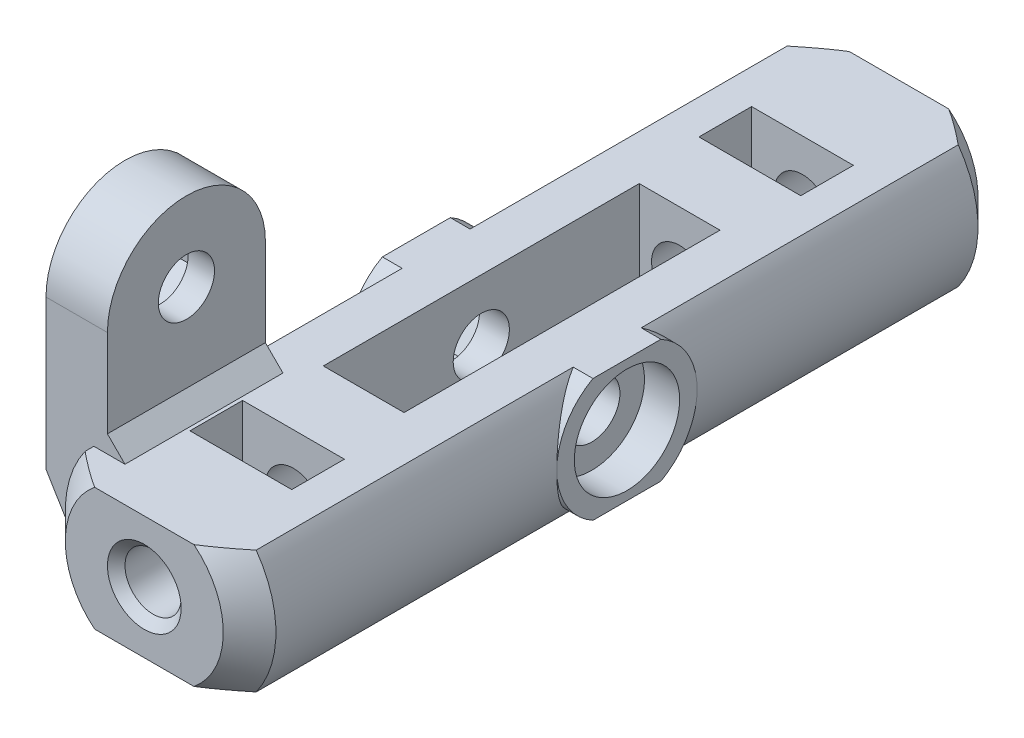
from build123d import *

# Parameters (mm, degrees)
BOSS_EXTRUDE1_DEPTH     = 21.5
BOSS_EXTRUDE2_DEPTH     = 6
CHAMFER1_SIZE           = 1.5
SKETCH2_W               = 4.6
SKETCH2_H               = 18
CUT_EXTRUDE1_DEPTH      = 4.5000001
CUT_EXTRUDE1_DEPTH_BACK = 4.5000001
SKETCH3_R               = 1.6
CUT_EXTRUDE2_DEPTH      = 16
CHAMFER2_SIZE           = 0.5
SKETCH4_R               = 1.6
CUT_EXTRUDE3_DEPTH      = 7.0000001
CUT_EXTRUDE3_DEPTH_BACK = 7.0000001
SKETCH6_R               = 3
CUT_EXTRUDE4_DEPTH      = 2
CUT_EXTRUDE5_DEPTH      = 2
BOSS_EXTRUDE3_START     = -4.1
SKETCH8_R               = 1.6
BOSS_EXTRUDE3_DEPTH     = 3.5
BOSS_EXTRUDE4_DEPTH     = 9
BOSS_EXTRUDE5_DEPTH     = 9
CUT_EXTRUDE6_DEPTH      = 2
SKETCH13_W              = 5.8
SKETCH13_H              = 3
CUT_EXTRUDE8_DEPTH      = 18.5


with BuildPart() as part:
    # Sketch1 → Boss-Extrude1 (new body, symmetric)
    with BuildSketch(Plane.XY):
        with BuildLine():
            Line((-4.873397172, 3.5), (4.873397172, 3.5))
            ThreePointArc((4.873397172, 3.5), (6, 0), (4.873397172, -3.5))
            Line((4.873397172, -3.5), (-4.873397172, -3.5))
            ThreePointArc((-4.873397172, -3.5), (-6, 0), (-4.873397172, 3.5))
        make_face()
    extrude(amount=BOSS_EXTRUDE1_DEPTH, both=True)

    # Sketch5 → Boss-Extrude2 (add, symmetric)
    with BuildSketch(Plane(origin=(0, 0, 0), x_dir=(0, 0, -1), z_dir=(1, 0, 0))):
        with BuildLine():
            Line((-1.936491673, 3.5), (1.936491673, 3.5))
            ThreePointArc((1.936491673, 3.5), (4, 0), (1.936491673, -3.5))
            Line((1.936491673, -3.5), (-1.936491673, -3.5))
            ThreePointArc((-1.936491673, -3.5), (-4, 0), (-1.936491673, 3.5))
        make_face()
    extrude(amount=BOSS_EXTRUDE2_DEPTH, both=True)

    # Chamfer1
    chamfer1_edges = [part.edges().sort_by_distance(p)[0] for p in [
        (-6, 0, 21.5),
        (6, 0, 21.5),
        (-6, 0, -21.5),
        (6, 0, -21.5),
    ]]
    chamfer(chamfer1_edges, length=CHAMFER1_SIZE)

    # Sketch2 → Cut-Extrude1 (cut, two sides)
    with BuildSketch(Plane(origin=(0, 0, 0), x_dir=(1, 0, 0), z_dir=(0, 1, 0))) as cut_extrude1_sk:
        Rectangle(SKETCH2_W, SKETCH2_H)
    extrude(amount=CUT_EXTRUDE1_DEPTH, mode=Mode.SUBTRACT)
    extrude(cut_extrude1_sk.sketch, amount=-CUT_EXTRUDE1_DEPTH_BACK, mode=Mode.SUBTRACT)

    # Sketch3 → Cut-Extrude2 (cut)
    with BuildSketch(Plane.XY.offset(21.5)):
        Circle(SKETCH3_R)
    cut_extrude2 = extrude(amount=-CUT_EXTRUDE2_DEPTH, mode=Mode.SUBTRACT)

    # Mirror2: Cut-Extrude2 across plane
    add(cut_extrude2.mirror(Plane.XY), mode=Mode.SUBTRACT)

    # Chamfer2
    chamfer2_edges = [part.edges().sort_by_distance(p)[0] for p in [
        (-1.6, 0, 21.5),
        (-1.6, 0, -21.5),
    ]]
    chamfer(chamfer2_edges, length=CHAMFER2_SIZE)

    # Sketch4 → Cut-Extrude3 (cut, two sides)
    with BuildSketch(Plane(origin=(0, 0, 0), x_dir=(0, 0, -1), z_dir=(1, 0, 0))) as cut_extrude3_sk:
        Circle(SKETCH4_R)
    extrude(amount=CUT_EXTRUDE3_DEPTH, mode=Mode.SUBTRACT)
    extrude(cut_extrude3_sk.sketch, amount=-CUT_EXTRUDE3_DEPTH_BACK, mode=Mode.SUBTRACT)

    # Sketch6 → Cut-Extrude4 (cut)
    with BuildSketch(Plane(origin=(6, 0, 0), x_dir=(0, 0, -1), z_dir=(1, 0, 0))):
        Circle(SKETCH6_R)
    extrude(amount=-CUT_EXTRUDE4_DEPTH, mode=Mode.SUBTRACT)

    # Sketch7 → Cut-Extrude5 (cut)
    with BuildSketch(Plane.ZY.offset(6)):
        Polygon((3.233161507, 0), (1.616580754, 2.8), (-1.616580754, 2.8), (-3.233161507, 0), (-1.616580754, -2.8), (1.616580754, -2.8), align=None)
    extrude(amount=-CUT_EXTRUDE5_DEPTH, mode=Mode.SUBTRACT)

    # Sketch8 → Boss-Extrude3 (add)
    with BuildSketch(Plane(origin=(0, 0, 0), x_dir=(0, 0, -1), z_dir=(1, 0, 0)).offset(BOSS_EXTRUDE3_START)):
        with BuildLine():
            Line((-19.5, 9.5), (-19.5, 1))
            Line((-19.5, 1), (-10.5, 1))
            Line((-10.5, 1), (-10.5, 9.5))
            ThreePointArc((-10.5, 9.5), (-15, 14), (-19.5, 9.5))
        make_face()
        with Locations((-15, 9.5)):
            Circle(SKETCH8_R, mode=Mode.SUBTRACT)
    extrude(amount=-BOSS_EXTRUDE3_DEPTH)

    # Sketch9 → Boss-Extrude4 (add)
    with BuildSketch(Plane.XY.offset(19.5)):
        Polygon((-7.6, 1), (-4.1, 1), (-4.873397172, -3.5), align=None)
    extrude(amount=-BOSS_EXTRUDE4_DEPTH)

    # Sketch10 → Boss-Extrude5 (add)
    with BuildSketch(Plane.XY.offset(19.5)):
        Polygon((-4.1, 4.5), (-3.1, 3.5), (-4.1, 3.5), align=None)
    extrude(amount=-BOSS_EXTRUDE5_DEPTH)

    # Sketch11 → Cut-Extrude6 (cut)
    with BuildSketch(Plane.ZY.offset(7.6)):
        Polygon((15, 6.151368439), (17.9, 7.825684219), (17.9, 11.174315781), (15, 12.848631561), (12.1, 11.174315781), (12.1, 7.825684219), align=None)
    extrude(amount=-CUT_EXTRUDE6_DEPTH, mode=Mode.SUBTRACT)

    # Sketch13 → Cut-Extrude8 (cut, through all)
    with BuildSketch(Plane.XZ.offset(3.5)):
        with Locations((0, 14.5)):
            Rectangle(SKETCH13_W, SKETCH13_H)
    cut_extrude8 = extrude(amount=-CUT_EXTRUDE8_DEPTH, mode=Mode.SUBTRACT)

    # Mirror4: Cut-Extrude8 across plane
    add(cut_extrude8.mirror(Plane.XY), mode=Mode.SUBTRACT)


solid = part.part
